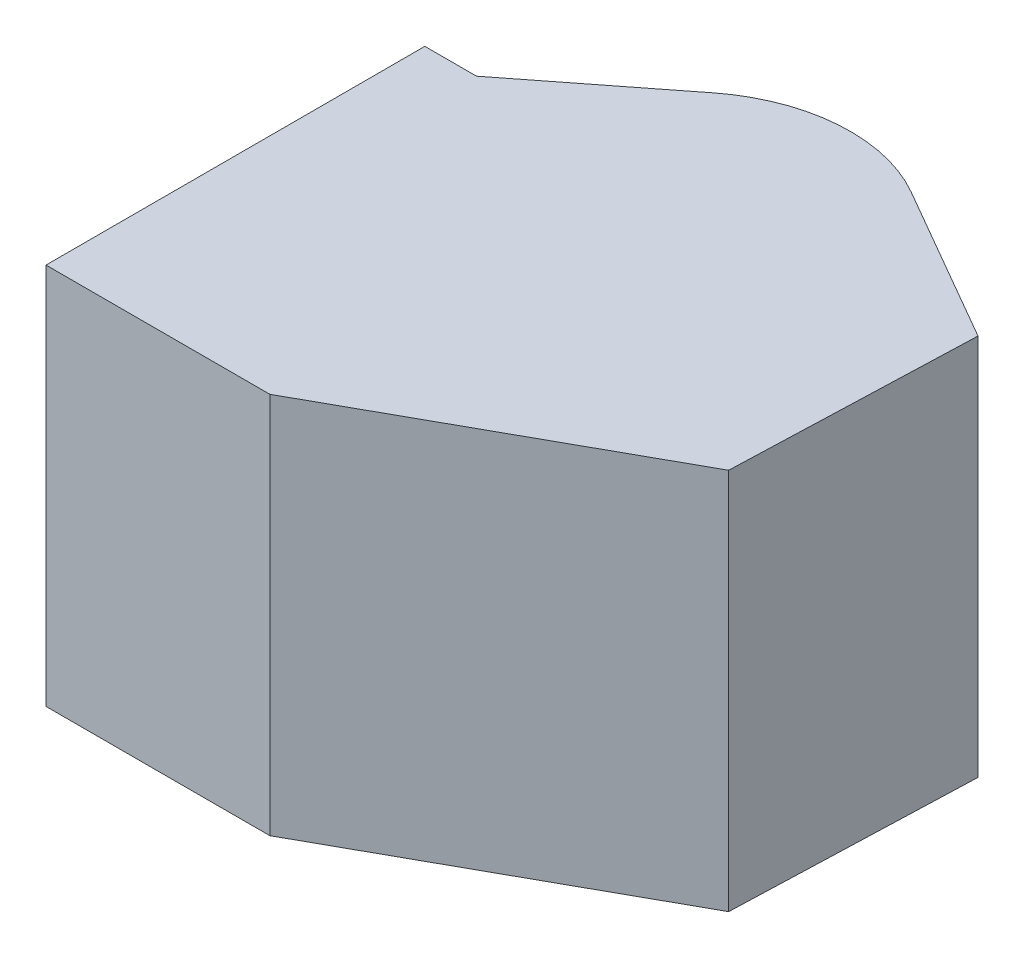
from build123d import *

# Parameters (mm, degrees)
BOSS_EXTRUDE1_DEPTH      = 55.5
BOSS_EXTRUDE1_DEPTH_BACK = 55.5
SKETCH2_R                = 45
BOSS_EXTRUDE2_DEPTH      = 10
FILLET1_R                = 3


with BuildPart() as part:
    # Sketch1 → Boss-Extrude1 (new body, two sides)
    with BuildSketch(Plane(origin=(0, 0, 0), x_dir=(1, 0, 0), z_dir=(0, 1, 0))) as boss_extrude1_sk:
        with BuildLine():
            Line((0, 0), (65, 0))
            Line((65, 0), (150.7127313, 47.511342784))
            Line((150.7127313, 47.511342784), (153.155696069, 117.468700675))
            Line((153.155696069, 117.468700675), (107.256349668, 143.968700675))
            ThreePointArc((107.256349668, 143.968700675), (79.846161337, 150.2914933), (53.590163022, 140.196014935))
            Line((53.590163022, 140.196014935), (15, 110))
            Line((15, 110), (0, 110))
            Line((0, 110), (0, 0))
        make_face()
    extrude(amount=BOSS_EXTRUDE1_DEPTH)
    extrude(boss_extrude1_sk.sketch, amount=-BOSS_EXTRUDE1_DEPTH_BACK)

    # Sketch2 → Boss-Extrude2 (add)
    with BuildSketch(Plane.ZY):
        with Locations((-55, 0)):
            Circle(SKETCH2_R)
    extrude(amount=BOSS_EXTRUDE2_DEPTH)

    # Fillet1
    fillet1_edges = [part.edges().sort_by_distance(p)[0] for p in [
        (0, 0, -100),
    ]]
    fillet(fillet1_edges, radius=FILLET1_R)


with BuildPart() as part_1:
    # Body-Move_Copy1: moved
    add(part.part.moved(Location((-83.217640918, 0, 55))))


solid = part_1.part
